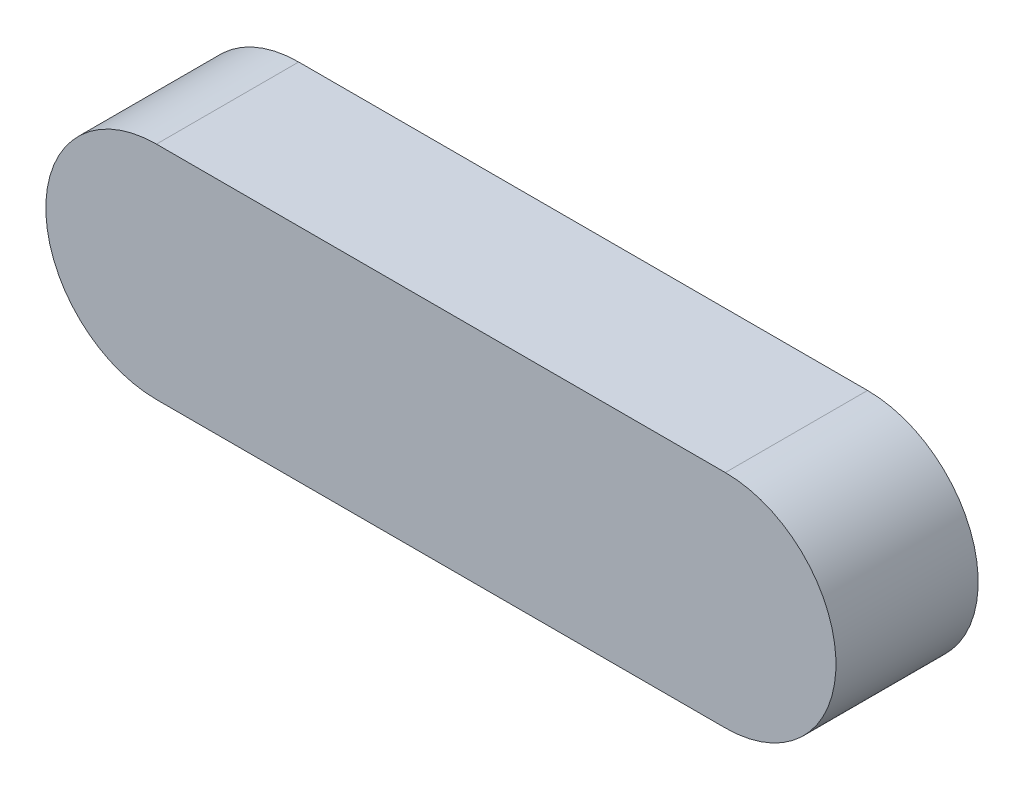
from build123d import *

# Parameters (mm, degrees)
BOSS_EXTRUDE1_DEPTH = 9


with BuildPart() as part:
    # Sketch1 → Boss-Extrude1 (new body)
    with BuildSketch(Plane.XY):
        with BuildLine():
            Line((0, 7), (36, 7))
            ThreePointArc((36, 7), (43, 0), (36, -7))
            Line((36, -7), (0, -7))
            ThreePointArc((0, -7), (-7, 0), (0, 7))
        make_face()
    extrude(amount=BOSS_EXTRUDE1_DEPTH)


solid = part.part
